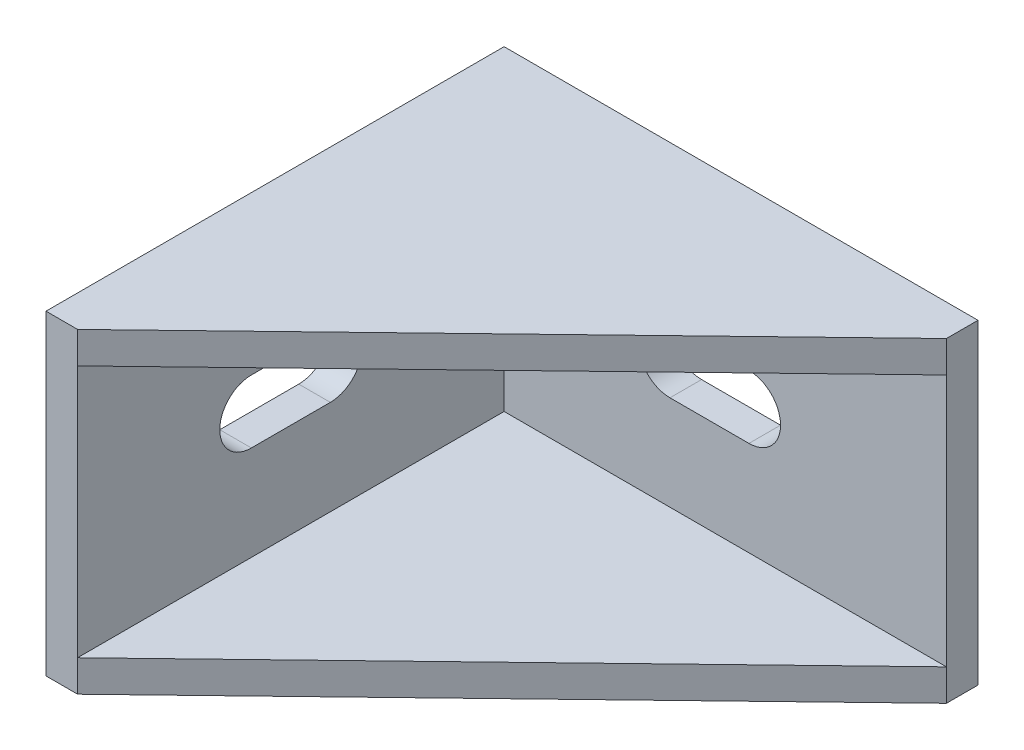
from build123d import *

# Parameters (mm, degrees)
ESQUISSE1_W             = 30
ESQUISSE1_H             = 20
BOSS_EXTRU_1_DEPTH      = 2
ESQUISSE2_W             = 2
ESQUISSE2_H             = 20
BOSS_EXTRU_2_DEPTH      = 27
ENL_V_MAT_EXTRU_1_DEPTH = 27
ENL_V_MAT_EXTRU_2_DEPTH = 27
BOSS_EXTRU_3_DEPTH      = 2
BOSS_EXTRU_4_DEPTH      = 2
BOSS_EXTRU_5_DEPTH      = 3
CONG_2_R                = 0.5
CONG_3_R                = 0.5


with BuildPart() as part:
    # Esquisse1 → Boss.-Extru.1 (new body)
    with BuildSketch(Plane.XY):
        Rectangle(ESQUISSE1_W, ESQUISSE1_H)
    extrude(amount=BOSS_EXTRU_1_DEPTH)

    # Esquisse2 → Boss.-Extru.2 (add)
    with BuildSketch(Plane.XY.offset(2)):
        with Locations((-14, 0)):
            Rectangle(ESQUISSE2_W, ESQUISSE2_H)
    extrude(amount=BOSS_EXTRU_2_DEPTH)

    # Esquisse3 → Enlèv. mat.-Extru.1 (cut)
    with BuildSketch(Plane.XY.offset(2)):
        with BuildLine():
            Line((-2.5, 2), (2.5, 2))
            ThreePointArc((2.5, 2), (4.5, 0), (2.5, -2))
            Line((2.5, -2), (-2.5, -2))
            ThreePointArc((-2.5, -2), (-4.5, 0), (-2.5, 2))
        make_face()
    extrude(amount=-ENL_V_MAT_EXTRU_1_DEPTH, mode=Mode.SUBTRACT)

    # Esquisse4 → Enlèv. mat.-Extru.2 (cut)
    with BuildSketch(Plane(origin=(-13, 0, 0), x_dir=(0, 0, -1), z_dir=(1, 0, 0))):
        with BuildLine():
            Line((-18, 2), (-13, 2))
            ThreePointArc((-13, 2), (-11, 0), (-13, -2))
            Line((-13, -2), (-18, -2))
            ThreePointArc((-18, -2), (-20, 0), (-18, 2))
        make_face()
    extrude(amount=-ENL_V_MAT_EXTRU_2_DEPTH, mode=Mode.SUBTRACT)

    # Esquisse5 → Boss.-Extru.3 (add)
    with BuildSketch(Plane(origin=(0, -10, 0), x_dir=(-1, 0, 0), z_dir=(0, -1, 0))):
        Polygon((13, -29), (-15, -2), (13, -2), align=None)
    extrude(amount=-BOSS_EXTRU_3_DEPTH)

    # Esquisse6 → Boss.-Extru.4 (add)
    with BuildSketch(Plane(origin=(0, 10, 0), x_dir=(1, 0, 0), z_dir=(0, 1, 0))):
        Polygon((15, -2), (-13, -29), (-13, -2), align=None)
    extrude(amount=-BOSS_EXTRU_4_DEPTH)

    # Esquisse7 → Boss.-Extru.5 (add)
    with BuildSketch(Plane(origin=(0, 0, 0), x_dir=(-1, 0, 0), z_dir=(0, 0, -1))):
        with BuildLine():
            Line((-11.75, -1), (-11.75, 1))
            ThreePointArc((-11.75, 1), (-9.75, 3), (-7.75, 1))
            Line((-7.75, 1), (-7.75, -1))
            ThreePointArc((-7.75, -1), (-9.75, -3), (-11.75, -1))
        make_face()
        with BuildLine():
            Line((7.75, -1), (7.75, 1))
            ThreePointArc((7.75, 1), (9.75, 3), (11.75, 1))
            Line((11.75, 1), (11.75, -1))
            ThreePointArc((11.75, -1), (9.75, -3), (7.75, -1))
        make_face()
    extrude(amount=BOSS_EXTRU_5_DEPTH)

    # Congé2
    cong_2_edges = [part.edges().sort_by_distance(p)[0] for p in [
        (9.75, -3, -3),
        (7.75, 0, -3),
        (9.75, 3, -3),
        (11.75, 0, -3),
    ]]
    fillet(cong_2_edges, radius=CONG_2_R)

    # Congé3
    cong_3_edges = [part.edges().sort_by_distance(p)[0] for p in [
        (-9.75, -3, -3),
        (-11.75, 0, -3),
        (-9.75, 3, -3),
        (-7.75, 0, -3),
    ]]
    fillet(cong_3_edges, radius=CONG_3_R)


solid = part.part
